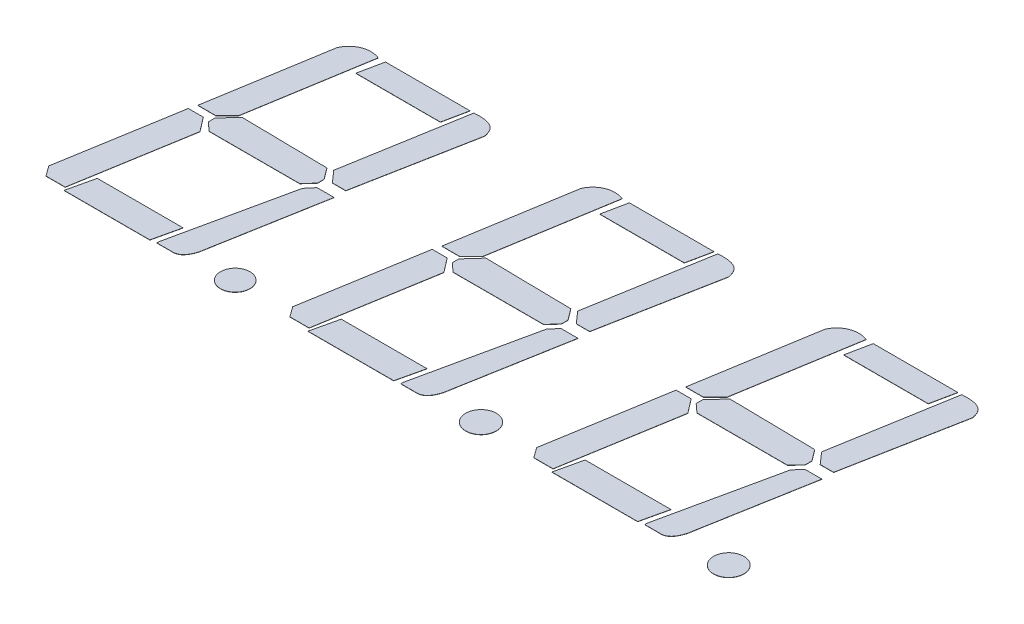
from build123d import *

# Parameters (mm, degrees)
SKETCH_1_R         = 0.763393416
EXTRUDE_1_DEPTH    = 0.01
SKETCH_1_R_2       = 0.795135379
EXTRUDE_1_2_DEPTH  = 0.01
SKETCH_1_R_3       = 0.787595702
EXTRUDE_1_3_DEPTH  = 0.01
EXTRUDE_1_4_DEPTH  = 0.01
EXTRUDE_1_5_DEPTH  = 0.01
EXTRUDE_1_6_DEPTH  = 0.01
EXTRUDE_1_7_DEPTH  = 0.01
EXTRUDE_1_8_DEPTH  = 0.01
EXTRUDE_1_9_DEPTH  = 0.01
EXTRUDE_1_10_DEPTH = 0.01
EXTRUDE_1_11_DEPTH = 0.01
EXTRUDE_1_12_DEPTH = 0.01
EXTRUDE_1_13_DEPTH = 0.01
EXTRUDE_1_14_DEPTH = 0.01
EXTRUDE_1_15_DEPTH = 0.01
EXTRUDE_1_16_DEPTH = 0.01
EXTRUDE_1_17_DEPTH = 0.01
EXTRUDE_1_18_DEPTH = 0.01
EXTRUDE_1_19_DEPTH = 0.01
EXTRUDE_1_20_DEPTH = 0.01
EXTRUDE_1_21_DEPTH = 0.01
EXTRUDE_1_22_DEPTH = 0.01
EXTRUDE_1_23_DEPTH = 0.01
EXTRUDE_1_24_DEPTH = 0.01


with BuildPart() as part:
    # Эскиз1 → Бобышка-Вытянуть1 (new body)
    with BuildSketch(Plane(origin=(0, 0, 0), x_dir=(1, 0, 0), z_dir=(0, 1, 0))):
        with Locations((-7.658623661, -7.816825486)):
            Circle(SKETCH_1_R)
    extrude(amount=EXTRUDE_1_DEPTH)


with BuildPart() as body_2:
    # Эскиз1 → Extrude 1 2 (new body)
    with BuildSketch(Plane(origin=(0, 0, 0), x_dir=(1, 0, 0), z_dir=(0, 1, 0))):
        with Locations((5.088592522, -7.816825486)):
            Circle(SKETCH_1_R_2)
    extrude(amount=EXTRUDE_1_2_DEPTH)


with BuildPart() as body_3:
    # Эскиз1 → Extrude 1 3 (new body)
    with BuildSketch(Plane(origin=(0, 0, 0), x_dir=(1, 0, 0), z_dir=(0, 1, 0))):
        with Locations((17.935397742, -7.816825486)):
            Circle(SKETCH_1_R_3)
    extrude(amount=EXTRUDE_1_3_DEPTH)


with BuildPart() as body_4:
    # Эскиз1 → Extrude 1 4 (new body)
    with BuildSketch(Plane(origin=(0, 0, 0), x_dir=(1, 0, 0), z_dir=(0, 1, 0))):
        with BuildLine():
            Line((-13.935399211, 5.877538867), (-14.953301559, -0.325303568))
            Line((-14.953301559, -0.325303568), (-15.557681079, -0.929683087))
            Line((-15.557681079, -0.929683087), (-16.480155082, -0.929683087))
            Line((-16.480155082, -0.929683087), (-15.464755195, 5.257909972))
            add(Edge.make_bspline(
                [(-13.935399211, 5.877538867), (-14.610385894, 6.138464398), (-15.237764212, 5.808302619), (-15.464755195, 5.257909972)],
                knots=[0, 0, 0, 0, 0.625517952, 0.625517952, 0.625517952, 0.625517952], degree=3))
        make_face()
    extrude(amount=EXTRUDE_1_4_DEPTH)


with BuildPart() as body_5:
    # Эскиз1 → Extrude 1 5 (new body)
    with BuildSketch(Plane(origin=(0, 0, 0), x_dir=(1, 0, 0), z_dir=(0, 1, 0))):
        Polygon((-13.561115101, 5.877538867), (-13.824242392, 4.605386618), (-9.438787541, 4.605386618), (-9.17566025, 5.877538867), align=None)
    extrude(amount=EXTRUDE_1_5_DEPTH)


with BuildPart() as body_6:
    # Эскиз1 → Extrude 1 6 (new body)
    with BuildSketch(Plane(origin=(0, 0, 0), x_dir=(1, 0, 0), z_dir=(0, 1, 0))):
        with BuildLine():
            Line((-8.976485421, 5.877538867), (-10.03976025, -0.325303568))
            Line((-10.03976025, -0.325303568), (-9.508122835, -0.929683087))
            Line((-9.508122835, -0.929683087), (-8.811752701, -0.929683087))
            Line((-8.811752701, -0.929683087), (-7.658623661, 5.142464503))
            add(Edge.make_bspline(
                [(-8.976485421, 5.877538867), (-7.789751397, 5.971425454), (-7.75409694, 5.437036419), (-7.658623661, 5.142464503)],
                knots=[0, 0, 0, 0, 0.49785116, 0.49785116, 0.49785116, 0.49785116], degree=3))
        make_face()
    extrude(amount=EXTRUDE_1_6_DEPTH)


with BuildPart() as body_7:
    # Эскиз1 → Extrude 1 7 (new body)
    with BuildSketch(Plane(origin=(0, 0, 0), x_dir=(1, 0, 0), z_dir=(0, 1, 0))):
        Polygon((-14.796386627, -0.325303568), (-15.464755195, -1.063631941), (-15.464755195, -1.404679905), (-15.020783216, -1.80658362), (-10.321650339, -1.80658362), (-9.883798455, -1.322900686), (-9.883798455, -0.982748319), (-10.321650339, -0.398715582), align=None)
    extrude(amount=EXTRUDE_1_7_DEPTH)


with BuildPart() as body_8:
    # Эскиз1 → Extrude 1 8 (new body)
    with BuildSketch(Plane(origin=(0, 0, 0), x_dir=(1, 0, 0), z_dir=(0, 1, 0))):
        Polygon((-15.808102822, -6.819203912), (-16.129603618, -8.221304608), (-11.682175934, -8.221304608), (-11.360675138, -6.819203912), align=None)
    extrude(amount=EXTRUDE_1_8_DEPTH)


with BuildPart() as body_9:
    # Эскиз1 → Extrude 1 9 (new body)
    with BuildSketch(Plane(origin=(0, 0, 0), x_dir=(1, 0, 0), z_dir=(0, 1, 0))):
        Polygon((-16.586311426, -1.322900686), (-17.623147785, -7.52025426), (-17.241957947, -8.046322143), (-16.246337063, -8.046322143), (-15.244523196, -2.058304174), (-15.808102822, -1.322900686), align=None)
    extrude(amount=EXTRUDE_1_9_DEPTH)


with BuildPart() as body_10:
    # Эскиз1 → Extrude 1 10 (new body)
    with BuildSketch(Plane(origin=(0, 0, 0), x_dir=(1, 0, 0), z_dir=(0, 1, 0))):
        with BuildLine():
            Line((-11.360675138, -8.046322143), (-10.03976025, -1.951571019))
            Line((-10.03976025, -1.951571019), (-9.694399155, -1.539885994))
            Line((-9.694399155, -1.539885994), (-8.811752701, -1.539885994))
            Line((-8.811752701, -1.539885994), (-9.867079703, -7.484095747))
            add(Edge.make_bspline(
                [(-9.867079703, -7.484095747), (-10.019377597, -7.965932222), (-10.239517084, -8.203702703), (-10.608927288, -8.174149887)],
                knots=[0, 0, 0, 0, 1, 1, 1, 1], degree=3))
            Line((-10.608927288, -8.174149887), (-11.360675138, -8.174149887))
            Line((-11.360675138, -8.174149887), (-11.360675138, -8.046322143))
        make_face()
    extrude(amount=EXTRUDE_1_10_DEPTH)


with BuildPart() as body_11:
    # Эскиз1 → Extrude 1 11 (new body)
    with BuildSketch(Plane(origin=(0, 0, 0), x_dir=(1, 0, 0), z_dir=(0, 1, 0))):
        with BuildLine():
            Line((-1.285399211, 5.877538867), (-2.303301559, -0.325303568))
            Line((-2.303301559, -0.325303568), (-2.907681079, -0.929683087))
            Line((-2.907681079, -0.929683087), (-3.830155082, -0.929683087))
            Line((-3.830155082, -0.929683087), (-2.814755195, 5.257909972))
            add(Edge.make_bspline(
                [(-1.285399211, 5.877538867), (-1.960385894, 6.138464398), (-2.587764212, 5.808302619), (-2.814755195, 5.257909972)],
                knots=[0, 0, 0, 0, 0.625517952, 0.625517952, 0.625517952, 0.625517952], degree=3))
        make_face()
    extrude(amount=EXTRUDE_1_11_DEPTH)


with BuildPart() as body_12:
    # Эскиз1 → Extrude 1 12 (new body)
    with BuildSketch(Plane(origin=(0, 0, 0), x_dir=(1, 0, 0), z_dir=(0, 1, 0))):
        Polygon((-0.911115101, 5.877538867), (-1.174242392, 4.605386618), (3.211212459, 4.605386618), (3.47433975, 5.877538867), align=None)
    extrude(amount=EXTRUDE_1_12_DEPTH)


with BuildPart() as body_13:
    # Эскиз1 → Extrude 1 13 (new body)
    with BuildSketch(Plane(origin=(0, 0, 0), x_dir=(1, 0, 0), z_dir=(0, 1, 0))):
        with BuildLine():
            Line((3.673514579, 5.877538867), (2.61023975, -0.325303568))
            Line((2.61023975, -0.325303568), (3.141877165, -0.929683087))
            Line((3.141877165, -0.929683087), (3.838247299, -0.929683087))
            Line((3.838247299, -0.929683087), (4.991376339, 5.142464503))
            add(Edge.make_bspline(
                [(3.673514579, 5.877538867), (4.860248603, 5.971425454), (4.89590306, 5.437036419), (4.991376339, 5.142464503)],
                knots=[0, 0, 0, 0, 0.49785116, 0.49785116, 0.49785116, 0.49785116], degree=3))
        make_face()
    extrude(amount=EXTRUDE_1_13_DEPTH)


with BuildPart() as body_14:
    # Эскиз1 → Extrude 1 14 (new body)
    with BuildSketch(Plane(origin=(0, 0, 0), x_dir=(1, 0, 0), z_dir=(0, 1, 0))):
        Polygon((-2.146386627, -0.325303568), (-2.814755195, -1.063631941), (-2.814755195, -1.404679905), (-2.370783216, -1.80658362), (2.328349661, -1.80658362), (2.766201545, -1.322900686), (2.766201545, -0.982748319), (2.328349661, -0.398715582), align=None)
    extrude(amount=EXTRUDE_1_14_DEPTH)


with BuildPart() as body_15:
    # Эскиз1 → Extrude 1 15 (new body)
    with BuildSketch(Plane(origin=(0, 0, 0), x_dir=(1, 0, 0), z_dir=(0, 1, 0))):
        Polygon((-3.158102822, -6.819203912), (-3.479603618, -8.221304608), (0.967824066, -8.221304608), (1.289324862, -6.819203912), align=None)
    extrude(amount=EXTRUDE_1_15_DEPTH)


with BuildPart() as body_16:
    # Эскиз1 → Extrude 1 16 (new body)
    with BuildSketch(Plane(origin=(0, 0, 0), x_dir=(1, 0, 0), z_dir=(0, 1, 0))):
        Polygon((-3.936311426, -1.322900686), (-4.973147785, -7.52025426), (-4.591957947, -8.046322143), (-3.596337063, -8.046322143), (-2.594523196, -2.058304174), (-3.158102822, -1.322900686), align=None)
    extrude(amount=EXTRUDE_1_16_DEPTH)


with BuildPart() as body_17:
    # Эскиз1 → Extrude 1 17 (new body)
    with BuildSketch(Plane(origin=(0, 0, 0), x_dir=(1, 0, 0), z_dir=(0, 1, 0))):
        with BuildLine():
            Line((1.289324862, -8.046322143), (2.61023975, -1.951571019))
            Line((2.61023975, -1.951571019), (2.955600845, -1.539885994))
            Line((2.955600845, -1.539885994), (3.838247299, -1.539885994))
            Line((3.838247299, -1.539885994), (2.782920297, -7.484095747))
            add(Edge.make_bspline(
                [(2.782920297, -7.484095747), (2.630622403, -7.965932222), (2.410482916, -8.203702703), (2.041072712, -8.174149887)],
                knots=[0, 0, 0, 0, 1, 1, 1, 1], degree=3))
            Line((2.041072712, -8.174149887), (1.289324862, -8.174149887))
            Line((1.289324862, -8.174149887), (1.289324862, -8.046322143))
        make_face()
    extrude(amount=EXTRUDE_1_17_DEPTH)


with BuildPart() as body_18:
    # Эскиз1 → Extrude 1 18 (new body)
    with BuildSketch(Plane(origin=(0, 0, 0), x_dir=(1, 0, 0), z_dir=(0, 1, 0))):
        with BuildLine():
            Line((11.364600789, 5.877538867), (10.346698441, -0.325303568))
            Line((10.346698441, -0.325303568), (9.742318921, -0.929683087))
            Line((9.742318921, -0.929683087), (8.819844918, -0.929683087))
            Line((8.819844918, -0.929683087), (9.835244805, 5.257909972))
            add(Edge.make_bspline(
                [(11.364600789, 5.877538867), (10.689614106, 6.138464398), (10.062235788, 5.808302619), (9.835244805, 5.257909972)],
                knots=[0, 0, 0, 0, 0.625517952, 0.625517952, 0.625517952, 0.625517952], degree=3))
        make_face()
    extrude(amount=EXTRUDE_1_18_DEPTH)


with BuildPart() as body_19:
    # Эскиз1 → Extrude 1 19 (new body)
    with BuildSketch(Plane(origin=(0, 0, 0), x_dir=(1, 0, 0), z_dir=(0, 1, 0))):
        Polygon((11.738884899, 5.877538867), (11.475757608, 4.605386618), (15.861212459, 4.605386618), (16.12433975, 5.877538867), align=None)
    extrude(amount=EXTRUDE_1_19_DEPTH)


with BuildPart() as body_20:
    # Эскиз1 → Extrude 1 20 (new body)
    with BuildSketch(Plane(origin=(0, 0, 0), x_dir=(1, 0, 0), z_dir=(0, 1, 0))):
        with BuildLine():
            Line((16.323514579, 5.877538867), (15.26023975, -0.325303568))
            Line((15.26023975, -0.325303568), (15.791877165, -0.929683087))
            Line((15.791877165, -0.929683087), (16.488247299, -0.929683087))
            Line((16.488247299, -0.929683087), (17.641376339, 5.142464503))
            add(Edge.make_bspline(
                [(16.323514579, 5.877538867), (17.510248603, 5.971425454), (17.54590306, 5.437036419), (17.641376339, 5.142464503)],
                knots=[0, 0, 0, 0, 0.49785116, 0.49785116, 0.49785116, 0.49785116], degree=3))
        make_face()
    extrude(amount=EXTRUDE_1_20_DEPTH)


with BuildPart() as body_21:
    # Эскиз1 → Extrude 1 21 (new body)
    with BuildSketch(Plane(origin=(0, 0, 0), x_dir=(1, 0, 0), z_dir=(0, 1, 0))):
        Polygon((10.503613373, -0.325303568), (9.835244805, -1.063631941), (9.835244805, -1.404679905), (10.279216784, -1.80658362), (14.978349661, -1.80658362), (15.416201545, -1.322900686), (15.416201545, -0.982748319), (14.978349661, -0.398715582), align=None)
    extrude(amount=EXTRUDE_1_21_DEPTH)


with BuildPart() as body_22:
    # Эскиз1 → Extrude 1 22 (new body)
    with BuildSketch(Plane(origin=(0, 0, 0), x_dir=(1, 0, 0), z_dir=(0, 1, 0))):
        Polygon((9.491897178, -6.819203912), (9.170396382, -8.221304608), (13.617824066, -8.221304608), (13.939324862, -6.819203912), align=None)
    extrude(amount=EXTRUDE_1_22_DEPTH)


with BuildPart() as body_23:
    # Эскиз1 → Extrude 1 23 (new body)
    with BuildSketch(Plane(origin=(0, 0, 0), x_dir=(1, 0, 0), z_dir=(0, 1, 0))):
        Polygon((8.713688574, -1.322900686), (7.676852215, -7.52025426), (8.058042053, -8.046322143), (9.053662937, -8.046322143), (10.055476804, -2.058304174), (9.491897178, -1.322900686), align=None)
    extrude(amount=EXTRUDE_1_23_DEPTH)


with BuildPart() as body_24:
    # Эскиз1 → Extrude 1 24 (new body)
    with BuildSketch(Plane(origin=(0, 0, 0), x_dir=(1, 0, 0), z_dir=(0, 1, 0))):
        with BuildLine():
            Line((13.939324862, -8.046322143), (15.26023975, -1.951571019))
            Line((15.26023975, -1.951571019), (15.605600845, -1.539885994))
            Line((15.605600845, -1.539885994), (16.488247299, -1.539885994))
            Line((16.488247299, -1.539885994), (15.432920297, -7.484095747))
            add(Edge.make_bspline(
                [(15.432920297, -7.484095747), (15.280622403, -7.965932222), (15.060482916, -8.203702703), (14.691072712, -8.174149887)],
                knots=[0, 0, 0, 0, 1, 1, 1, 1], degree=3))
            Line((14.691072712, -8.174149887), (13.939324862, -8.174149887))
            Line((13.939324862, -8.174149887), (13.939324862, -8.046322143))
        make_face()
    extrude(amount=EXTRUDE_1_24_DEPTH)


solid = Compound([part.part, body_2.part, body_3.part, body_4.part, body_5.part, body_6.part, body_7.part, body_8.part, body_9.part, body_10.part, body_11.part, body_12.part, body_13.part, body_14.part, body_15.part, body_16.part, body_17.part, body_18.part, body_19.part, body_20.part, body_21.part, body_22.part, body_23.part, body_24.part])
